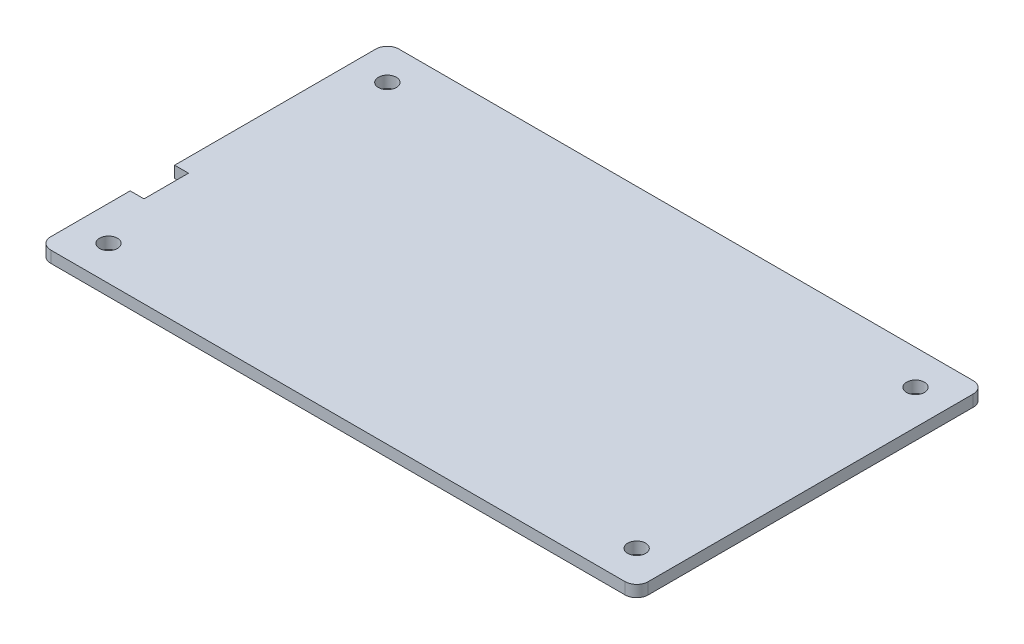
from build123d import *

# Parameters (mm, degrees)
SKETCH_1_R      = 1.55
EXTRUDE_1_DEPTH = 2


with BuildPart() as part:
    # 草图1 → 凸台-拉伸1 (new body)
    with BuildSketch(Plane(origin=(0, 0, 0), x_dir=(1, 0, 0), z_dir=(0, 1, 0))):
        with BuildLine():
            Line((97.46, -4), (97.46, 52.29))
            ThreePointArc((97.46, 52.29), (96.874213562, 53.704213562), (95.46, 54.29))
            Line((95.46, 54.29), (-4, 54.29))
            ThreePointArc((-4, 54.29), (-5.414213562, 53.704213562), (-6, 52.29))
            Line((-6, 52.29), (-6, 17.45))
            Line((-6, 17.45), (-3.6, 17.45))
            Line((-3.6, 17.45), (-3.6, 9.75))
            Line((-3.6, 9.75), (-6, 9.75))
            Line((-6, 9.75), (-6, -4))
            ThreePointArc((-6, -4), (-5.414213562, -5.414213562), (-4, -6))
            Line((-4, -6), (95.46, -6))
            ThreePointArc((95.46, -6), (96.874213562, -5.414213562), (97.46, -4))
        make_face()
        Circle(SKETCH_1_R, mode=Mode.SUBTRACT)
        with Locations((91.46, 0)):
            Circle(SKETCH_1_R, mode=Mode.SUBTRACT)
        with Locations((0, 48.29)):
            Circle(SKETCH_1_R, mode=Mode.SUBTRACT)
        with Locations((91.46, 48.29)):
            Circle(SKETCH_1_R, mode=Mode.SUBTRACT)
    extrude(amount=EXTRUDE_1_DEPTH)


solid = part.part
